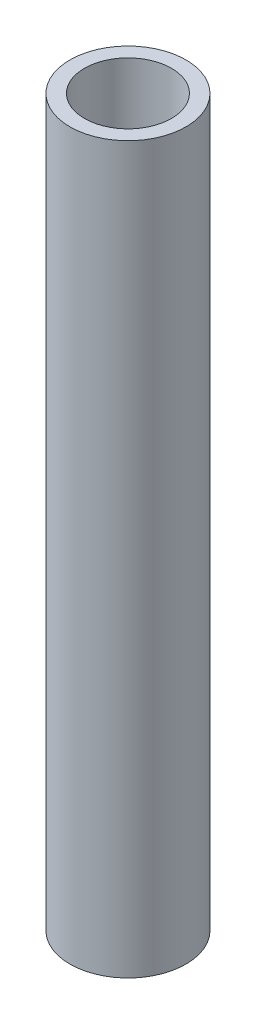
from build123d import *

# Parameters (mm, degrees)
SKETCH_1_R      = 2
SKETCH_1_R_2    = 1.5
EXTRUDE_1_DEPTH = 25


with BuildPart() as part:
    # 草图1 → 凸台-拉伸1 (new body)
    with BuildSketch(Plane(origin=(0, 0, 0), x_dir=(1, 0, 0), z_dir=(0, 1, 0))):
        Circle(SKETCH_1_R)
        Circle(SKETCH_1_R_2, mode=Mode.SUBTRACT)
    extrude(amount=EXTRUDE_1_DEPTH)


solid = part.part
